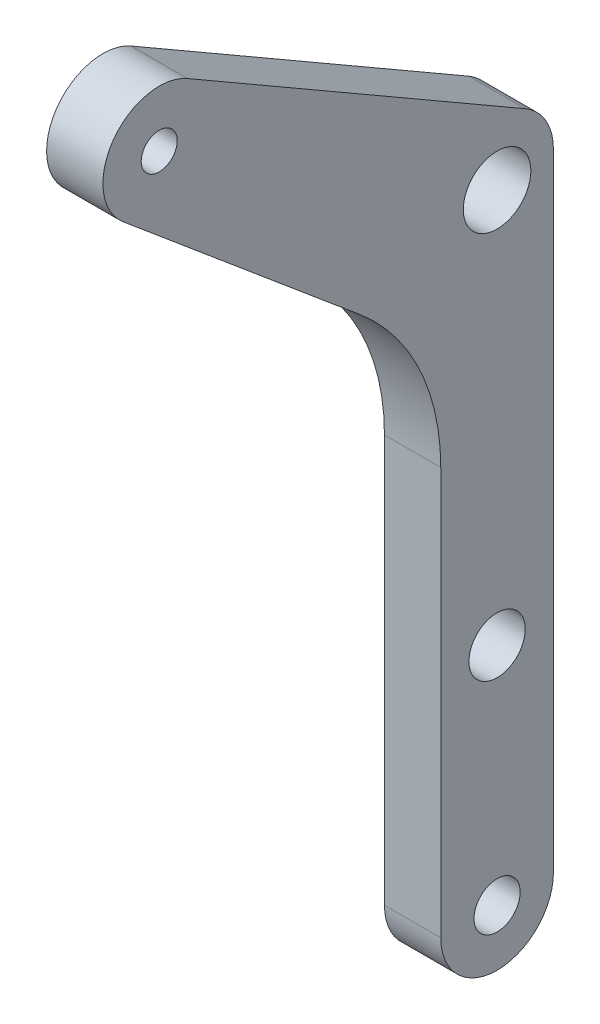
from build123d import *

# Parameters (mm, degrees)
SKETCH_1_R          = 2.05
SKETCH_1_R_2        = 2.5
SKETCH_1_R_3        = 3
SKETCH_1_R_4        = 1.6
EXTRUDE_1_DEPTH     = 5
SKETCH_2_R          = 2.25
CUT_EXTRUDE_1_DEPTH = 1.5


with BuildPart() as part:
    # 草图1 → 凸台-拉伸1 (new body)
    with BuildSketch(Plane(origin=(0, 0, 0), x_dir=(0, 0, -1), z_dir=(1, 0, 0))):
        with BuildLine():
            Line((5, 0), (5, 55.679491924))
            ThreePointArc((5, 55.679491924), (4.330127019, 58.179491924), (2.5, 60.009618943))
            Line((2.5, 60.009618943), (-27.5, 77.330127019))
            ThreePointArc((-27.5, 77.330127019), (-34.095760221, 75.867882182), (-33.213938048, 69.169777784))
            Line((-33.213938048, 69.169777784), (-12.144247806, 51.490208473))
            ThreePointArc((-12.144247806, 51.490208473), (-6.873844259, 44.621684846), (-5, 36.169319611))
            Line((-5, 36.169319611), (-5, 0))
            ThreePointArc((-5, 0), (0, -5), (5, 0))
        make_face()
        Circle(SKETCH_1_R, mode=Mode.SUBTRACT)
        with Locations((0, 20)):
            Circle(SKETCH_1_R_2, mode=Mode.SUBTRACT)
        with Locations((0, 55)):
            Circle(SKETCH_1_R_3, mode=Mode.SUBTRACT)
        with Locations((-30, 73)):
            Circle(SKETCH_1_R_4, mode=Mode.SUBTRACT)
    extrude(amount=EXTRUDE_1_DEPTH)

    # 草图2 → 切除-拉伸1 (cut)
    with BuildSketch(Plane.ZY):
        with Locations((30, 73)):
            Circle(SKETCH_2_R)
    extrude(amount=-CUT_EXTRUDE_1_DEPTH, mode=Mode.SUBTRACT)


solid = part.part
